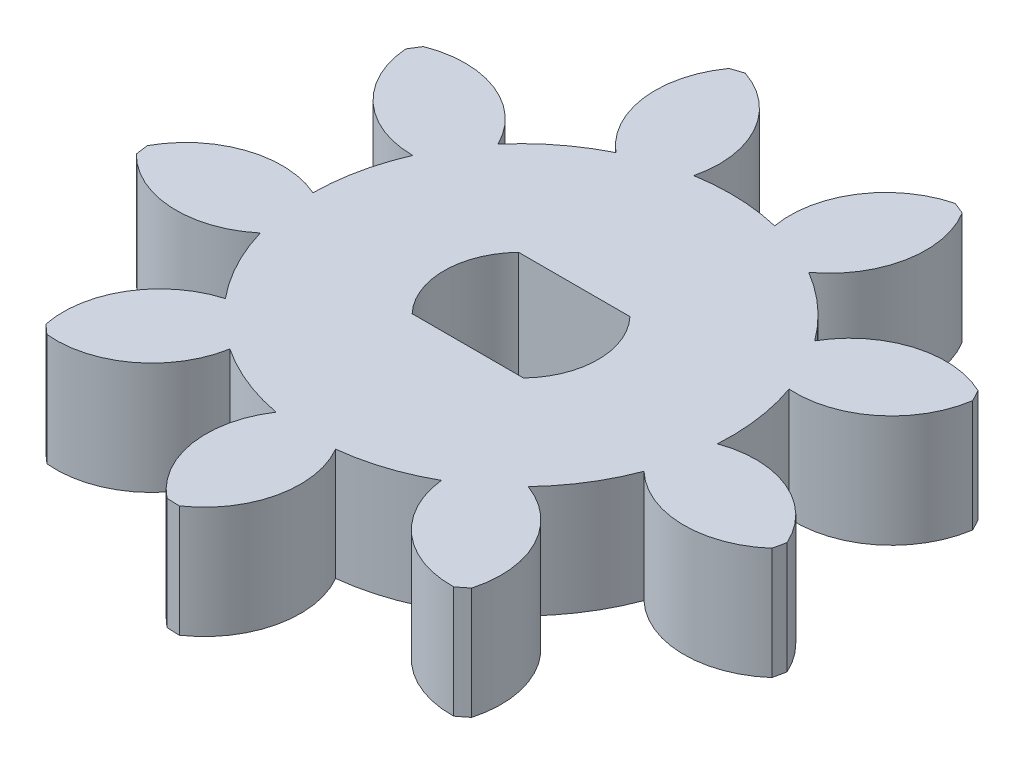
from build123d import *

# Parameters (mm, degrees)
SALIENTE_EXTRUIR1_DEPTH = 4


with BuildPart() as part:
    # Croquis3 → Saliente-Extruir1 (new body)
    with BuildSketch(Plane(origin=(0, 0, 0), x_dir=(1, 0, 0), z_dir=(0, 1, 0))):
        with BuildLine():
            ThreePointArc((402.347998687, -260.746007142), (404.734398392, -259.99334246), (405.982912796, -257.824790071))
            ThreePointArc((405.982912796, -257.824790071), (405.877105548, -257.620612188), (405.7674051, -257.418499365))
            ThreePointArc((405.7674051, -257.418499365), (403.271107475, -257.23416883), (401.314373797, -258.795153423))
            ThreePointArc((401.314373797, -258.795153423), (400.302743654, -257.677442632), (399.088021884, -256.784624632))
            ThreePointArc((399.088021884, -256.784624632), (400.432306585, -254.674101872), (399.9948055, -252.210364776))
            ThreePointArc((399.9948055, -252.210364776), (399.782509433, -252.121967031), (399.568558396, -252.037653715))
            ThreePointArc((399.568558396, -252.037653715), (397.537798087, -253.501037517), (397.042234682, -255.954585253))
            ThreePointArc((397.042234682, -255.954585253), (395.548830385, -255.748632435), (394.044407175, -255.845502269))
            ThreePointArc((394.044407175, -255.845502269), (393.71757112, -253.364658487), (391.798766166, -251.758546653))
            ThreePointArc((391.798766166, -251.758546653), (391.579316968, -251.827291333), (391.36122541, -251.900228661))
            ThreePointArc((391.36122541, -251.900228661), (390.746217737, -254.326593255), (391.943704228, -256.524661881))
            ThreePointArc((391.943704228, -256.524661881), (390.667306245, -257.326834648), (389.577117935, -258.368065845))
            ThreePointArc((389.577117935, -258.368065845), (387.732091346, -256.677715418), (385.229812687, -256.680746422))
            ThreePointArc((385.229812687, -256.680746422), (385.105893077, -256.874467128), (384.985708462, -257.070526914))
            ThreePointArc((384.985708462, -257.070526914), (386.074222349, -259.324549341), (388.404441499, -260.238638117))
            ThreePointArc((388.404441499, -260.238638117), (387.942290632, -261.673590916), (387.776448448, -263.171979827))
            ThreePointArc((387.776448448, -263.171979827), (385.276539772, -263.063056507), (383.361631401, -264.673812109))
            ThreePointArc((383.361631401, -264.673812109), (383.391224742, -264.901864769), (383.425182787, -265.12930846))
            ThreePointArc((383.425182787, -265.12930846), (385.707890489, -266.156306575), (388.080506861, -265.358703205))
            ThreePointArc((388.080506861, -265.358703205), (388.648848637, -266.755005674), (389.484951979, -268.009439474))
            ThreePointArc((389.484951979, -268.009439474), (387.499896269, -269.532909692), (387.068365096, -271.997699444))
            ThreePointArc((387.068365096, -271.997699444), (387.237624334, -272.153375684), (387.409835692, -272.305779849))
            ThreePointArc((387.409835692, -272.305779849), (389.818632906, -271.625209821), (391.123472929, -269.489121785))
            ThreePointArc((391.123472929, -269.489121785), (392.456373915, -270.193428481), (393.903200739, -270.616943654))
            ThreePointArc((393.903200739, -270.616943654), (393.361827622, -273.059958764), (394.615591878, -275.225480148))
            ThreePointArc((394.615591878, -275.225480148), (394.845318735, -275.235937326), (395.075203798, -275.241990362))
            ThreePointArc((395.075203798, -275.241990362), (396.482987537, -273.172298471), (396.109502064, -270.697225101))
            ThreePointArc((396.109502064, -270.697225101), (397.583283074, -270.379983093), (398.963847028, -269.774412182))
            ThreePointArc((398.963847028, -269.774412182), (400.119471003, -271.993858263), (402.471880459, -272.846839757))
            ThreePointArc((402.471880459, -272.846839757), (402.654583186, -272.707184842), (402.834576178, -272.564054467))
            ThreePointArc((402.834576178, -272.564054467), (402.582628784, -270.07367255), (400.705575818, -268.417728184))
            ThreePointArc((400.705575818, -268.417728184), (401.630638339, -267.227378533), (402.298958206, -265.876074898))
            ThreePointArc((402.298958206, -265.876074898), (404.610849972, -266.833448463), (406.961186099, -265.974770545))
            ThreePointArc((406.961186099, -265.974770545), (407.011376059, -265.750349625), (407.057256258, -265.525008131))
            ThreePointArc((407.057256258, -265.525008131), (405.263466718, -263.779213565), (402.761140203, -263.717232975))
            ThreePointArc((402.761140203, -263.717232975), (402.7046372, -262.210753513), (402.347998687, -260.746007142))
        make_face()
        with BuildLine():
            Line((397.264195322, -265.143672214), (393.288016252, -265.143672214))
            ThreePointArc((393.288016252, -265.143672214), (392.526105787, -263.243672214), (393.288016252, -261.343672214))
            Line((393.288016252, -261.343672214), (397.264195322, -261.343672214))
            ThreePointArc((397.264195322, -261.343672214), (398.026105787, -263.243672214), (397.264195322, -265.143672214))
        make_face(mode=Mode.SUBTRACT)
    extrude(amount=SALIENTE_EXTRUIR1_DEPTH)


solid = part.part
